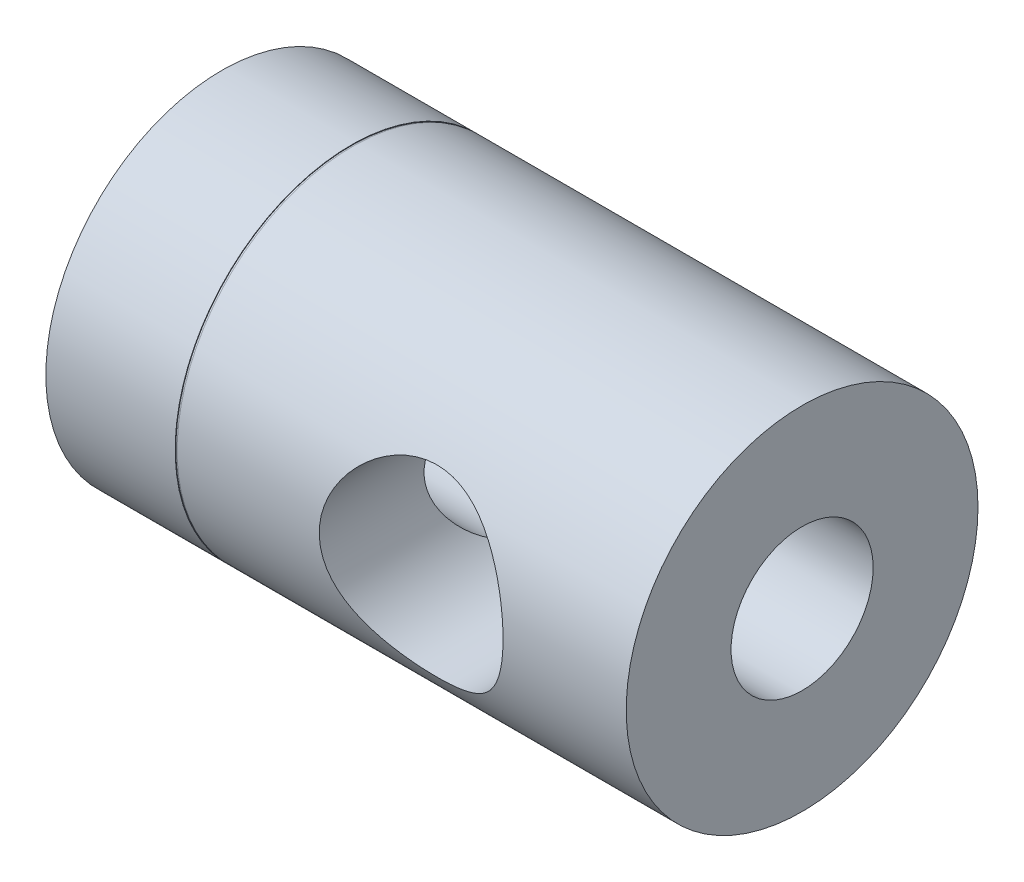
from build123d import *

# Parameters (mm, degrees)
SKETCH2_R               = 4.9276
CUT_EXTRUDE1_DEPTH      = 10.42975
CUT_EXTRUDE1_DEPTH_BACK = 10.42975


with BuildPart() as part:
    # Sketch1 → Revolve1 (revolve)
    with BuildSketch(Plane.XY):
        Polygon((-1.7145, 3.81), (15.6845, 3.81), (15.6845, 9.42975), (-8.3947, 9.42975), (-8.3947, 9.398), (-8.4455, 9.398), (-8.4963, 9.398), (-8.4963, 9.42975), (-15.4305, 9.42975), (-19.1135, 3.81), align=None)
    revolve(axis=Axis((0, 0, 0), (-1, 0, 0)))

    # Sketch2 → Cut-Extrude1 (cut, two sides)
    with BuildSketch(Plane.XY) as cut_extrude1_sk:
        with Locations((4.1529, 0)):
            Circle(SKETCH2_R)
    extrude(amount=CUT_EXTRUDE1_DEPTH, mode=Mode.SUBTRACT)
    extrude(cut_extrude1_sk.sketch, amount=-CUT_EXTRUDE1_DEPTH_BACK, mode=Mode.SUBTRACT)


solid = part.part
